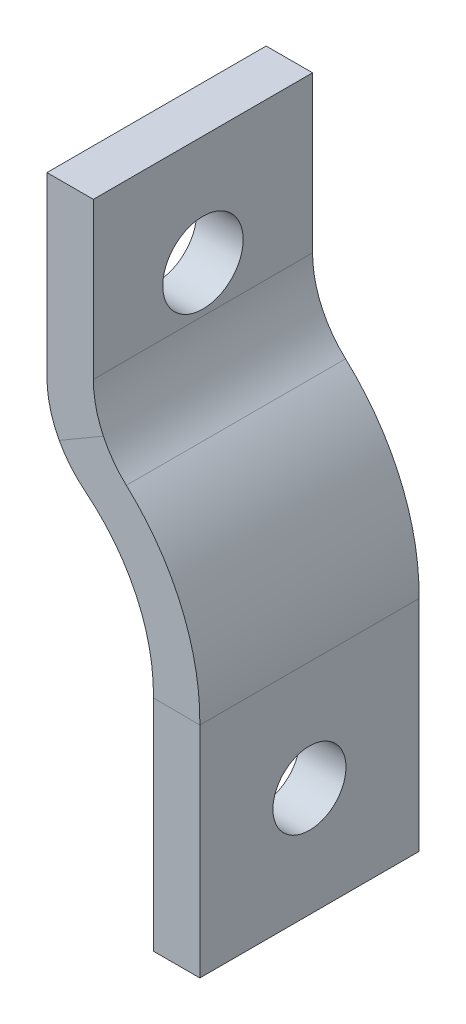
from build123d import *

# Parameters (mm, degrees)
FILLET1_R               = 7
M5_CLEARANCE_HOLE1_D    = 5.5
CUT_EXTRUDE1_DEPTH      = 37.52886072966826
CUT_EXTRUDE1_DEPTH_BACK = 37.52886072966826
SKETCH3_R               = 2.4999999999999996


with BuildPart() as part:
    # Sweep1: sweep along a path in Sketch1
    with BuildLine(Plane.XY) as sweep1_path:
        Line((-14.2875, 7.5), (-14.2875, -7.5))
        ThreePointArc((-14.2875, -7.5), (-8.903716825795872, -12.735560659438995), (-7.000000000000001, -20))
        Line((-7.000000000000001, -20), (-6.999999999999999, -35))
    # Sketch2 → Sweep1 (sweep)
    with BuildSketch(Plane(origin=(0, 0, 0), x_dir=(1, 0, 0), z_dir=(0, 1, 0))):
        Polygon((-12.699999999999996, -7.499999999999996), (-15.874999999999996, -7.499999999999996), (-15.874999999999996, 7.500000000000004), (-12.699999999999996, 7.500000000000005), align=None)
    sweep(path=sweep1_path.line, transition=Transition.RIGHT)

    # Fillet1
    fillet1_edges = [part.edges().sort_by_distance(p)[0] for p in [
        (-15.874999999999996, -8.441785890670294, -1.599e-14),
        (-12.699999999999996, -6.5917812273426035, -7.11e-15),
    ]]
    fillet(fillet1_edges, radius=FILLET1_R)

    # M5 Clearance Hole1 (through all)
    with Locations(Plane.ZY.offset(15.874999999999996)):
        with Locations((0, 0)):
            Hole(M5_CLEARANCE_HOLE1_D / 2)

    # Sketch3 → Cut-Extrude1 (cut, two sides: drawn at the far end of the back side and taken through both)
    with BuildSketch(Plane.ZY.offset(8.587500000000007).offset(-CUT_EXTRUDE1_DEPTH_BACK)):
        with Locations(Location((0, -27.500000000000004, 0), (0, 0, 270))):
            Circle(SKETCH3_R)
    extrude(amount=CUT_EXTRUDE1_DEPTH + CUT_EXTRUDE1_DEPTH_BACK, mode=Mode.SUBTRACT)


solid = part.part
